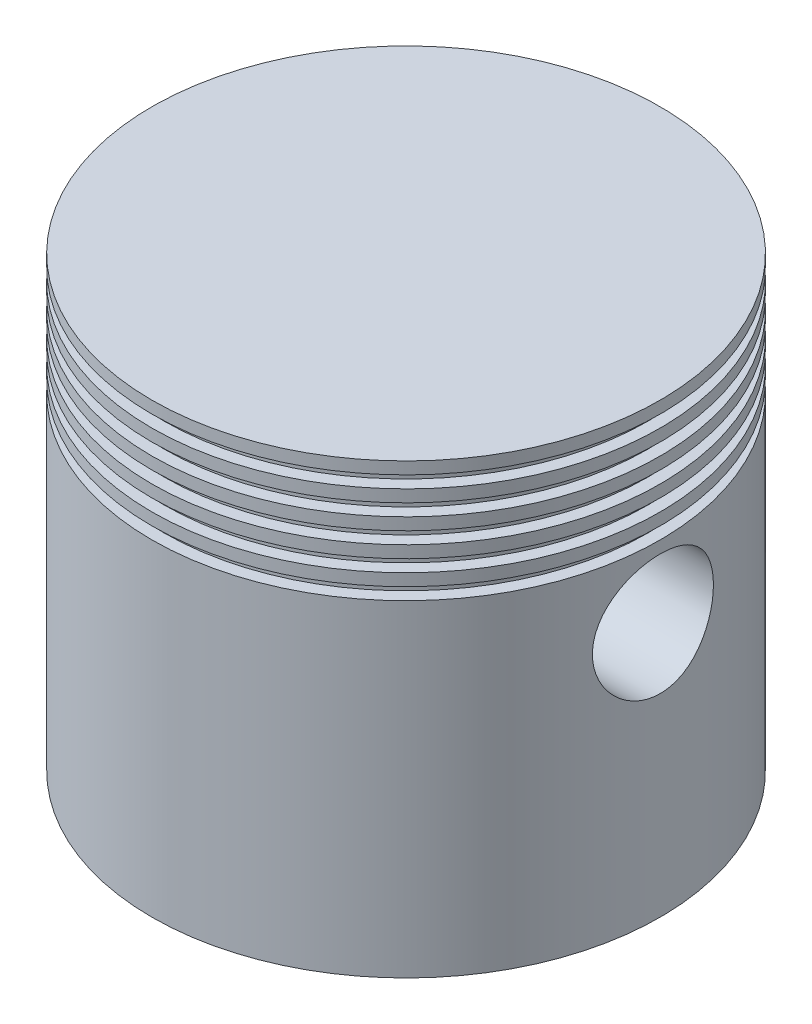
from build123d import *

# Parameters (mm, degrees)
SKETCH2_R               = 10.5
BOSS_EXTRUDE1_DEPTH     = 18.5
CUT_EXTRUDE1_DEPTH      = 16.5
SKETCH4_R               = 2.5
CUT_EXTRUDE2_DEPTH      = 11.5
CUT_EXTRUDE2_DEPTH_BACK = 11.5
SKETCH5_W               = 0.5
SKETCH5_H               = 0.5
LPATTERN1_COUNT         = 5
LPATTERN1_PITCH         = 1


with BuildPart() as part:
    # Sketch2 → Boss-Extrude1 (new body)
    with BuildSketch(Plane(origin=(0, 0, 0), x_dir=(1, 0, 0), z_dir=(0, 1, 0))):
        with Locations(Location((0, 0, 0), (0, 0, 270))):  # turned: the seam where the file's is
            Circle(SKETCH2_R)
    extrude(amount=-BOSS_EXTRUDE1_DEPTH)

    # Sketch3 → Cut-Extrude1 (cut)
    with BuildSketch(Plane.XZ.offset(18.5)):
        with BuildLine():
            Line((-6.25, 6.475916923), (-6.25, -6.475916923))
            ThreePointArc((-6.25, -6.475916923), (0, -9), (6.25, -6.475916923))
            Line((6.25, -6.475916923), (6.25, 6.475916923))
            ThreePointArc((6.25, 6.475916923), (0, 9), (-6.25, 6.475916923))
        make_face()
    extrude(amount=-CUT_EXTRUDE1_DEPTH, mode=Mode.SUBTRACT)

    # Sketch4 → Cut-Extrude2 (cut, two sides)
    with BuildSketch(Plane(origin=(0, 0, 0), x_dir=(0, 0, -1), z_dir=(1, 0, 0))) as cut_extrude2_sk:
        with Locations(Location((0, -8, 0), (0, 0, 90))):  # turned: the seam where the file's is
            Circle(SKETCH4_R)
    extrude(amount=CUT_EXTRUDE2_DEPTH, mode=Mode.SUBTRACT)
    extrude(cut_extrude2_sk.sketch, amount=-CUT_EXTRUDE2_DEPTH_BACK, mode=Mode.SUBTRACT)

    # Sketch5 → Cut-Revolve1 (revolve, cut)
    with BuildSketch(Plane(origin=(0, 0, 0), x_dir=(0, 0, -1), z_dir=(1, 0, 0)), mode=Mode.PRIVATE) as cut_revolve1_sk:
        with Locations((10.25, -0.75)):
            Rectangle(SKETCH5_W, SKETCH5_H)
    cut_revolve1 = revolve(cut_revolve1_sk.sketch.rotate(Axis((0, 0, 0), (0, -1, 0)), 180), axis=Axis((0, 0, 0), (0, -1, 0)), mode=Mode.SUBTRACT)  # turned: the seam where the file's is

    # LPattern1: Cut-Revolve1 ×5
    with Locations(*[(0, -i * LPATTERN1_PITCH, 0) for i in range(1, LPATTERN1_COUNT)]):
        add(cut_revolve1, mode=Mode.SUBTRACT)


solid = part.part
